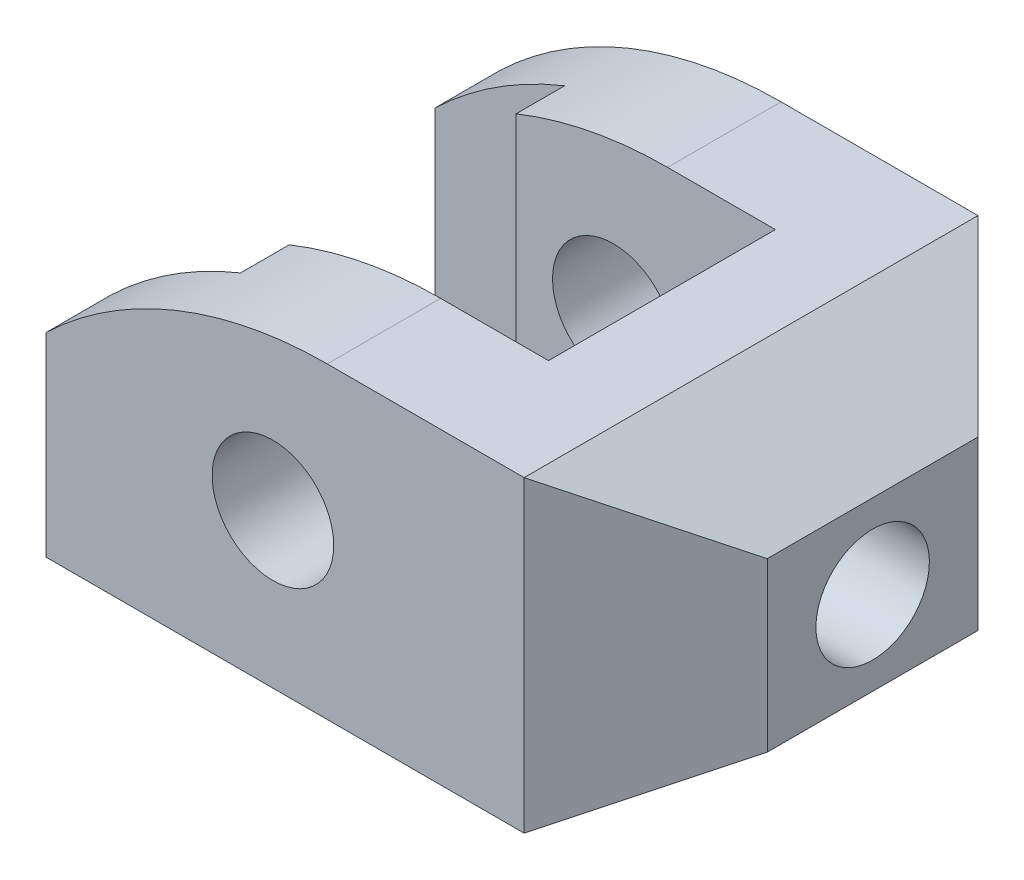
from build123d import *

# Parameters (mm, degrees)
SKETCH1_R           = 7.5
BOSS_EXTRUDE1_DEPTH = 56
CUT_EXTRUDE1_DEPTH  = 38
SKETCH3_R           = 7
CUT_EXTRUDE2_DEPTH  = 26


with BuildPart() as part:
    # Sketch1 → Boss-Extrude1 (new body)
    with BuildSketch(Plane.XY):
        with BuildLine():
            Line((-28, -19), (31, -19))
            Line((31, -19), (46, -10.339745962))
            Line((46, -10.339745962), (46, 10.339745962))
            Line((46, 10.339745962), (31, 19))
            Line((31, 19), (6.698703146, 19))
            ThreePointArc((6.698703146, 19), (-12.009583788, 15.368092477), (-28, 5))
            Line((-28, 5), (-28, -19))
        make_face()
        Circle(SKETCH1_R, mode=Mode.SUBTRACT)
    extrude(amount=BOSS_EXTRUDE1_DEPTH)

    # Sketch2 → Cut-Extrude1 (cut)
    with BuildSketch(Plane(origin=(0, 19, 0), x_dir=(1, 0, 0), z_dir=(0, 1, 0))):
        Polygon((31, 0), (46, -15), (46, 0), align=None)
        Polygon((31, -56), (46, -41), (46, -56), align=None)
        Polygon((-28, -8), (-12, -8), (-12, -14), (20, -14), (20, -42), (-12, -42), (-12, -48), (-28, -48), align=None)
    extrude(amount=-CUT_EXTRUDE1_DEPTH, mode=Mode.SUBTRACT)

    # Sketch3 → Cut-Extrude2 (cut)
    with BuildSketch(Plane(origin=(46, 0, 0), x_dir=(0, 0, -1), z_dir=(1, 0, 0))):
        with Locations((-28, 0)):
            Circle(SKETCH3_R)
    extrude(amount=-CUT_EXTRUDE2_DEPTH, mode=Mode.SUBTRACT)


solid = part.part
